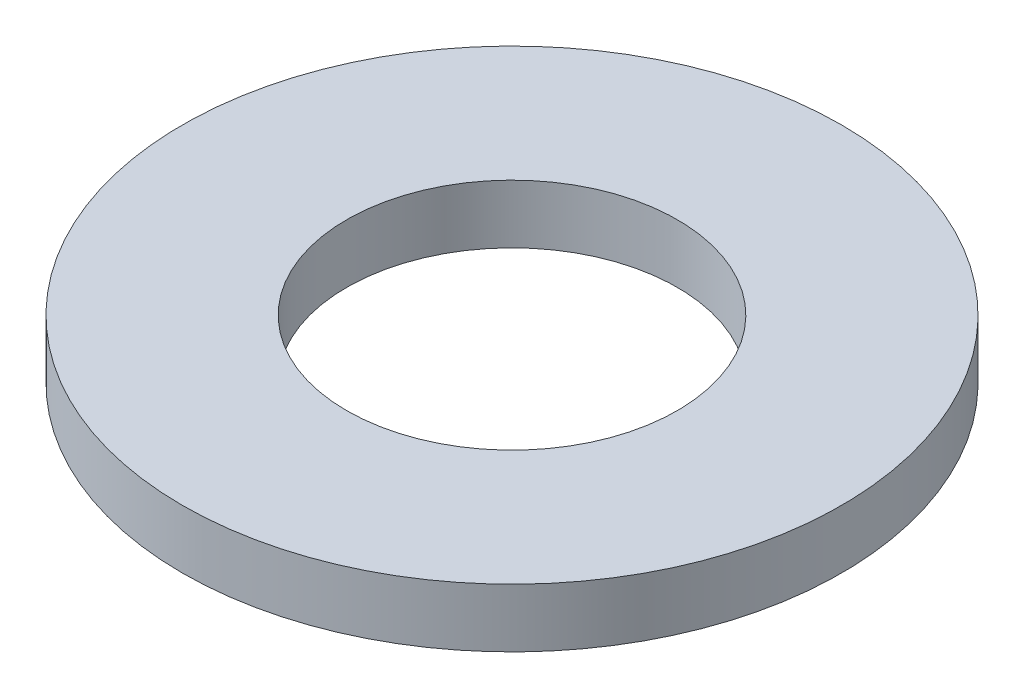
from build123d import *

# Parameters (mm, degrees)
SKETCH1_R           = 3.5687
BOSS_EXTRUDE1_DEPTH = 0.635
SKETCH5_R           = 1.7907
CUT_EXTRUDE1_DEPTH  = 6.086694838


with BuildPart() as part:
    # Sketch1 → Boss-Extrude1 (new body)
    with BuildSketch(Plane(origin=(0, 0, 0), x_dir=(1, 0, 0), z_dir=(0, 1, 0))):
        Circle(SKETCH1_R)
    extrude(amount=BOSS_EXTRUDE1_DEPTH)

    # Sketch5 → Cut-Extrude1 (cut, through all)
    with BuildSketch(Plane(origin=(0, 0.635, 0), x_dir=(-1, 0, 0), z_dir=(0, 1, 0))):
        Circle(SKETCH5_R)
    extrude(amount=-CUT_EXTRUDE1_DEPTH, mode=Mode.SUBTRACT)


solid = part.part
